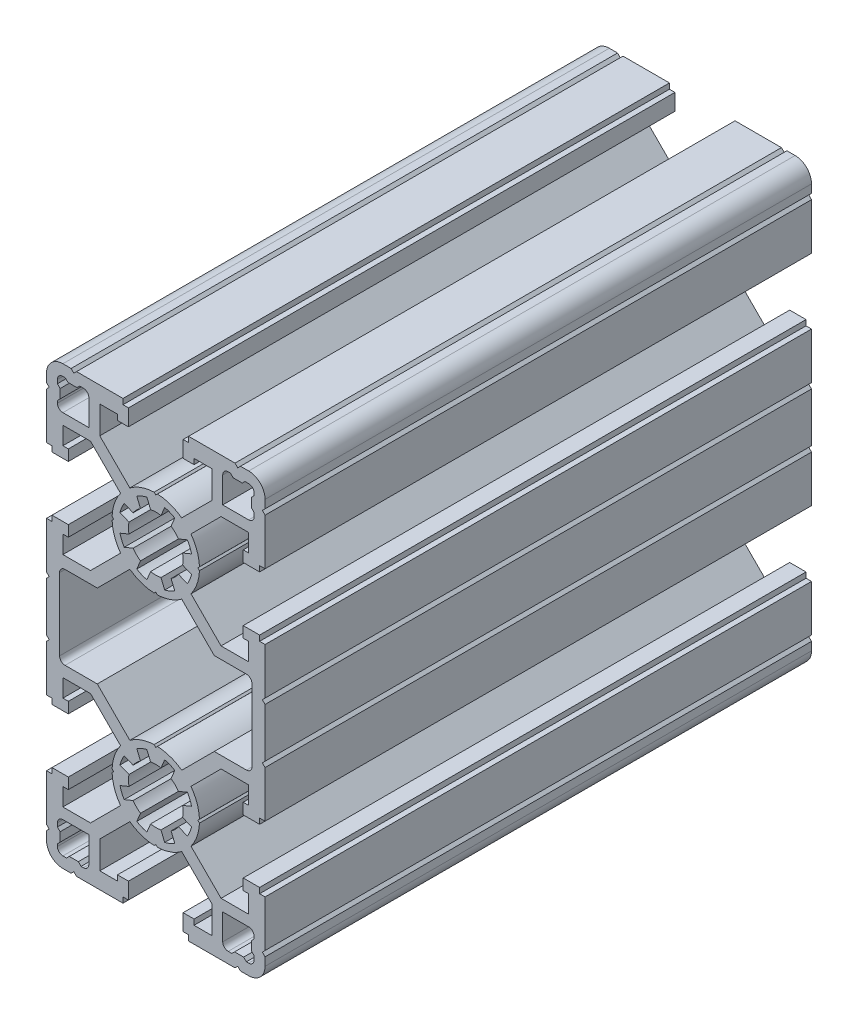
from build123d import *

# Parameters (mm, degrees)
Y_KSEKLIK_EKSTR_ZYON1_DEPTH = 100


with BuildPart() as part:
    # Çizim1 → Yükseklik-Ekstrüzyon1 (new body)
    with BuildSketch(Plane.XY.offset(100)):
        with BuildLine():
            Line((5, 35.999999999), (7.000000001, 35.999999999))
            Line((7.000000001, 35.999999999), (7.000000001, 36.999999999))
            Line((7.000000001, 36.999999999), (10.25, 36.999999999))
            Line((10.25, 36.999999999), (10.25, 31.947056271))
            Line((10.25, 31.947056271), (4.744324446, 26.441380719))
            ThreePointArc((4.744324446, 26.441380719), (2.642011935, 27.551143818), (0.30640597, 27.994130059))
            Line((0.30640597, 27.994130059), (1e-09, 27.700000001))
            Line((1e-09, 27.700000001), (-0.30640597, 27.994130059))
            ThreePointArc((-0.30640597, 27.994130059), (-2.642011934, 27.551143817), (-4.744324444, 26.441380719))
            Line((-4.744324444, 26.441380719), (-10.249999999, 31.947056274))
            Line((-10.249999999, 31.947056274), (-10.249999999, 36.999999999))
            Line((-10.249999999, 36.999999999), (-6.999999999, 36.999999999))
            Line((-6.999999999, 36.999999999), (-6.999999999, 35.999999999))
            Line((-6.999999999, 35.999999999), (-5, 35.999999999))
            Line((-5, 35.999999999), (-5, 39))
            Line((-5, 39), (-6, 39))
            Line((-6, 39), (-6, 40))
            Line((-6, 40), (-14.5, 40))
            Line((-14.5, 40), (-15, 39.5))
            Line((-15, 39.5), (-15.5, 40))
            Line((-15.5, 40), (-17, 40))
            ThreePointArc((-17, 40), (-19.121320344, 39.121320344), (-20, 37))
            Line((-20, 37), (-20, 35.5))
            Line((-20, 35.5), (-19.5, 35))
            Line((-19.5, 35), (-20, 34.5))
            Line((-20, 34.5), (-20, 26))
            Line((-20, 26), (-19, 26))
            Line((-19, 26), (-19, 25))
            Line((-19, 25), (-16, 25))
            Line((-16, 25), (-16, 27))
            Line((-16, 27), (-17, 27))
            Line((-17, 27), (-17, 30.25))
            Line((-17, 30.25), (-11.947056274, 30.25))
            Line((-11.947056274, 30.25), (-6.441380718, 24.744324445))
            ThreePointArc((-6.441380718, 24.744324445), (-7.551143816, 22.642011934), (-7.994130057, 20.30640597))
            Line((-7.994130057, 20.30640597), (-7.699999999, 20.000000001))
            Line((-7.699999999, 20.000000001), (-7.994130057, 19.69359403))
            ThreePointArc((-7.994130057, 19.69359403), (-7.551143816, 17.357988067), (-6.441380718, 15.255675557))
            Line((-6.441380718, 15.255675557), (-11.947056276, 9.75))
            Line((-11.947056276, 9.75), (-17, 9.75))
            Line((-17, 9.75), (-17, 13))
            Line((-17, 13), (-16, 13))
            Line((-16, 13), (-16, 15))
            Line((-16, 15), (-19, 15))
            Line((-19, 15), (-19, 14))
            Line((-19, 14), (-20, 14))
            Line((-20, 14), (-20, 5.5))
            Line((-20, 5.5), (-19.5, 5))
            Line((-19.5, 5), (-20, 4.5))
            Line((-20, 4.5), (-20, -4.5))
            Line((-20, -4.5), (-19.5, -5))
            Line((-19.5, -5), (-20, -5.5))
            Line((-20, -5.5), (-20, -14))
            Line((-20, -14), (-19, -14))
            Line((-19, -14), (-19, -15))
            Line((-19, -15), (-16, -15))
            Line((-16, -15), (-16, -13))
            Line((-16, -13), (-17, -13))
            Line((-17, -13), (-17, -9.750000001))
            Line((-17, -9.750000001), (-11.947056274, -9.750000001))
            Line((-11.947056274, -9.750000001), (-6.441380718, -15.255675557))
            ThreePointArc((-6.441380718, -15.255675557), (-7.551143816, -17.357988067), (-7.994130057, -19.69359403))
            Line((-7.994130057, -19.69359403), (-7.699999999, -20.000000001))
            Line((-7.699999999, -20.000000001), (-7.994130057, -20.30640597))
            ThreePointArc((-7.994130057, -20.30640597), (-7.551143816, -22.642011934), (-6.441380718, -24.744324445))
            Line((-6.441380718, -24.744324445), (-11.947056274, -30.25))
            Line((-11.947056274, -30.25), (-17, -30.25))
            Line((-17, -30.25), (-17, -27))
            Line((-17, -27), (-16, -27))
            Line((-16, -27), (-16, -25))
            Line((-16, -25), (-19, -25))
            Line((-19, -25), (-19, -26))
            Line((-19, -26), (-20, -26))
            Line((-20, -26), (-20, -34.5))
            Line((-20, -34.5), (-19.5, -35))
            Line((-19.5, -35), (-20, -35.5))
            Line((-20, -35.5), (-20, -37))
            ThreePointArc((-20, -37), (-19.121320344, -39.121320344), (-17, -40))
            Line((-17, -40), (-15.5, -40))
            Line((-15.5, -40), (-15, -39.5))
            Line((-15, -39.5), (-14.5, -40))
            Line((-14.5, -40), (-6, -40))
            Line((-6, -40), (-6, -39))
            Line((-6, -39), (-5, -39))
            Line((-5, -39), (-5, -36.000000001))
            Line((-5, -36.000000001), (-6.999999999, -36.000000001))
            Line((-6.999999999, -36.000000001), (-6.999999999, -37.000000001))
            Line((-6.999999999, -37.000000001), (-10.249999999, -37.000000001))
            Line((-10.249999999, -37.000000001), (-10.249999999, -31.947056276))
            Line((-10.249999999, -31.947056276), (-4.744324443, -26.44138072))
            ThreePointArc((-4.744324443, -26.44138072), (-2.642011933, -27.551143818), (-0.30640597, -27.994130059))
            Line((-0.30640597, -27.994130059), (1e-09, -27.700000001))
            Line((1e-09, -27.700000001), (0.30640597, -27.994130059))
            ThreePointArc((0.30640597, -27.994130059), (2.642011934, -27.551143818), (4.744324444, -26.441380721))
            Line((4.744324444, -26.441380721), (10.25, -31.947056276))
            Line((10.25, -31.947056276), (10.25, -37.000000001))
            Line((10.25, -37.000000001), (7.000000001, -37.000000001))
            Line((7.000000001, -37.000000001), (7.000000001, -36.000000001))
            Line((7.000000001, -36.000000001), (5, -36.000000001))
            Line((5, -36.000000001), (5, -39))
            Line((5, -39), (6, -39))
            Line((6, -39), (6, -40))
            Line((6, -40), (14.5, -40))
            Line((14.5, -40), (15, -39.5))
            Line((15, -39.5), (15.5, -40))
            Line((15.5, -40), (17, -40))
            ThreePointArc((17, -40), (19.121320344, -39.121320344), (20, -37))
            Line((20, -37), (20, -35.5))
            Line((20, -35.5), (19.5, -35))
            Line((19.5, -35), (20, -34.5))
            Line((20, -34.5), (20, -26))
            Line((20, -26), (19, -26))
            Line((19, -26), (19, -25))
            Line((19, -25), (16, -25))
            Line((16, -25), (16, -27))
            Line((16, -27), (17, -27))
            Line((17, -27), (17, -30.25))
            Line((17, -30.25), (11.947056275, -30.25))
            Line((11.947056275, -30.25), (6.44138072, -24.744324445))
            ThreePointArc((6.44138072, -24.744324445), (7.551143818, -22.642011935), (7.994130059, -20.306405972))
            Line((7.994130059, -20.306405972), (7.700000001, -20.000000001))
            Line((7.700000001, -20.000000001), (7.994130059, -19.693594032))
            ThreePointArc((7.994130059, -19.693594032), (7.551143818, -17.357988068), (6.44138072, -15.255675556))
            Line((6.44138072, -15.255675556), (11.947056275, -9.750000001))
            Line((11.947056275, -9.750000001), (17, -9.750000001))
            Line((17, -9.750000001), (17, -13))
            Line((17, -13), (16, -13))
            Line((16, -13), (16, -15))
            Line((16, -15), (19, -15))
            Line((19, -15), (19, -14))
            Line((19, -14), (20, -14))
            Line((20, -14), (20, -5.5))
            Line((20, -5.5), (19.5, -5))
            Line((19.5, -5), (20, -4.5))
            Line((20, -4.5), (20, 4.5))
            Line((20, 4.5), (19.5, 5))
            Line((19.5, 5), (20, 5.5))
            Line((20, 5.5), (20, 14))
            Line((20, 14), (19, 14))
            Line((19, 14), (19, 15))
            Line((19, 15), (16, 15))
            Line((16, 15), (16, 13))
            Line((16, 13), (17, 13))
            Line((17, 13), (17, 9.75))
            Line((17, 9.75), (11.947056273, 9.75))
            Line((11.947056273, 9.75), (6.441380719, 15.255675555))
            ThreePointArc((6.441380719, 15.255675555), (7.551143818, 17.357988067), (7.994130059, 19.693594032))
            Line((7.994130059, 19.693594032), (7.700000001, 20.000000001))
            Line((7.700000001, 20.000000001), (7.994130059, 20.306405972))
            ThreePointArc((7.994130059, 20.306405972), (7.551143818, 22.642011935), (6.44138072, 24.744324445))
            Line((6.44138072, 24.744324445), (11.947056275, 30.25))
            Line((11.947056275, 30.25), (17, 30.25))
            Line((17, 30.25), (17, 27))
            Line((17, 27), (16, 27))
            Line((16, 27), (16, 25))
            Line((16, 25), (19, 25))
            Line((19, 25), (19, 26))
            Line((19, 26), (20, 26))
            Line((20, 26), (20, 34.5))
            Line((20, 34.5), (19.5, 35))
            Line((19.5, 35), (20, 35.5))
            Line((20, 35.5), (20, 37))
            ThreePointArc((20, 37), (19.121320344, 39.121320344), (17, 40))
            Line((17, 40), (15.5, 40))
            Line((15.5, 40), (15, 39.5))
            Line((15, 39.5), (14.5, 40))
            Line((14.5, 40), (6, 40))
            Line((6, 40), (6, 39))
            Line((6, 39), (5, 39))
            Line((5, 39), (5, 35.999999999))
        make_face()
        with BuildLine():
            Line((1.630729447, -26.550055075), (0.950878753, -24.90875031))
            ThreePointArc((0.950878753, -24.90875031), (1e-09, -25.000000001), (-0.950878752, -24.90875031))
            Line((-0.950878752, -24.90875031), (-1.630729446, -26.550055075))
            ThreePointArc((-1.630729446, -26.550055075), (-2.583113167, -26.236186846), (-3.478488509, -25.784688211))
            Line((-3.478488509, -25.784688211), (-2.798637815, -24.143383446))
            ThreePointArc((-2.798637815, -24.143383446), (-3.535533905, -23.535533907), (-4.143383444, -22.798637818))
            Line((-4.143383444, -22.798637818), (-5.784688209, -23.478488512))
            ThreePointArc((-5.784688209, -23.478488512), (-6.236186844, -22.583113169), (-6.550055074, -21.630729446))
            Line((-6.550055074, -21.630729446), (-4.908750309, -20.950878752))
            ThreePointArc((-4.908750309, -20.950878752), (-4.999999999, -20), (-4.908750308, -19.049121248))
            Line((-4.908750308, -19.049121248), (-6.550055073, -18.369270554))
            ThreePointArc((-6.550055073, -18.369270554), (-6.236186844, -17.416886832), (-5.784688209, -16.52151149))
            Line((-5.784688209, -16.52151149), (-4.143383444, -17.201362184))
            ThreePointArc((-4.143383444, -17.201362184), (-3.535533905, -16.464466095), (-2.798637816, -15.856616556))
            Line((-2.798637816, -15.856616556), (-3.47848851, -14.215311791))
            ThreePointArc((-3.47848851, -14.215311791), (-2.583113167, -13.763813156), (-1.630729443, -13.449944926))
            Line((-1.630729443, -13.449944926), (-0.95087875, -15.091249691))
            ThreePointArc((-0.95087875, -15.091249691), (2e-09, -15.000000001), (0.950878753, -15.091249691))
            Line((0.950878753, -15.091249691), (1.630729447, -13.449944926))
            ThreePointArc((1.630729447, -13.449944926), (2.58311317, -13.763813156), (3.478488512, -14.215311791))
            Line((3.478488512, -14.215311791), (2.798637818, -15.856616556))
            ThreePointArc((2.798637818, -15.856616556), (3.535533907, -16.464466095), (4.143383446, -17.201362184))
            Line((4.143383446, -17.201362184), (5.784688211, -16.52151149))
            ThreePointArc((5.784688211, -16.52151149), (6.236186846, -17.416886832), (6.550055075, -18.369270554))
            Line((6.550055075, -18.369270554), (4.90875031, -19.049121248))
            ThreePointArc((4.90875031, -19.049121248), (5.000000001, -20.000000001), (4.90875031, -20.950878754))
            Line((4.90875031, -20.950878754), (6.550055075, -21.630729448))
            ThreePointArc((6.550055075, -21.630729448), (6.236186845, -22.58311317), (5.78468821, -23.478488513))
            Line((5.78468821, -23.478488513), (4.143383445, -22.798637819))
            ThreePointArc((4.143383445, -22.798637819), (3.535533907, -23.535533907), (2.798637818, -24.143383446))
            Line((2.798637818, -24.143383446), (3.478488511, -25.784688211))
            ThreePointArc((3.478488511, -25.784688211), (2.583113169, -26.236186846), (1.630729447, -26.550055075))
        make_face(mode=Mode.SUBTRACT)
        with BuildLine():
            Line((17, -38), (16.578427125, -38))
            Line((16.578427125, -38), (16.078427125, -37.5))
            Line((16.078427125, -37.5), (14.421572875, -37.5))
            Line((14.421572875, -37.5), (13.921572875, -38))
            Line((13.921572875, -38), (13.25, -38))
            ThreePointArc((13.25, -38), (12.542893219, -37.707106781), (12.25, -37))
            Line((12.25, -37), (12.25, -32.25))
            Line((12.25, -32.25), (17, -32.25))
            ThreePointArc((17, -32.25), (17.707106781, -32.542893219), (18, -33.25))
            Line((18, -33.25), (18, -33.671572875))
            Line((18, -33.671572875), (17.5, -34.171572875))
            Line((17.5, -34.171572875), (17.5, -35.828427125))
            Line((17.5, -35.828427125), (18, -36.328427125))
            Line((18, -36.328427125), (18, -37))
            ThreePointArc((18, -37), (17.707106781, -37.707106781), (17, -38))
        make_face(mode=Mode.SUBTRACT)
        with BuildLine():
            Line((-18, -37), (-18, -36.578427125))
            Line((-18, -36.578427125), (-17.5, -36.078427125))
            Line((-17.5, -36.078427125), (-17.5, -34.421572875))
            Line((-17.5, -34.421572875), (-18, -33.921572875))
            Line((-18, -33.921572875), (-18, -33.25))
            ThreePointArc((-18, -33.25), (-17.707106781, -32.542893219), (-17, -32.25))
            Line((-17, -32.25), (-12.25, -32.25))
            Line((-12.25, -32.25), (-12.25, -37))
            ThreePointArc((-12.25, -37), (-12.542893219, -37.707106781), (-13.25, -38))
            Line((-13.25, -38), (-13.671572875, -38))
            Line((-13.671572875, -38), (-14.171572875, -37.5))
            Line((-14.171572875, -37.5), (-15.828427125, -37.5))
            Line((-15.828427125, -37.5), (-16.328427125, -38))
            Line((-16.328427125, -38), (-17, -38))
            ThreePointArc((-17, -38), (-17.707106781, -37.707106781), (-18, -37))
        make_face(mode=Mode.SUBTRACT)
        with BuildLine():
            Line((18, 37), (18, 36.578427125))
            Line((18, 36.578427125), (17.5, 36.078427125))
            Line((17.5, 36.078427125), (17.5, 34.421572875))
            Line((17.5, 34.421572875), (18, 33.921572875))
            Line((18, 33.921572875), (18, 33.25))
            ThreePointArc((18, 33.25), (17.707106781, 32.542893219), (17, 32.25))
            Line((17, 32.25), (12.25, 32.25))
            Line((12.25, 32.25), (12.25, 37))
            ThreePointArc((12.25, 37), (12.542893219, 37.707106781), (13.25, 38))
            Line((13.25, 38), (13.671572875, 38))
            Line((13.671572875, 38), (14.171572875, 37.5))
            Line((14.171572875, 37.5), (15.828427125, 37.5))
            Line((15.828427125, 37.5), (16.328427125, 38))
            Line((16.328427125, 38), (17, 38))
            ThreePointArc((17, 38), (17.707106781, 37.707106781), (18, 37))
        make_face(mode=Mode.SUBTRACT)
        with BuildLine():
            Line((-17, 38), (-16.578427125, 38))
            Line((-16.578427125, 38), (-16.078427125, 37.5))
            Line((-16.078427125, 37.5), (-14.421572875, 37.5))
            Line((-14.421572875, 37.5), (-13.921572875, 38))
            Line((-13.921572875, 38), (-13.25, 38))
            ThreePointArc((-13.25, 38), (-12.542893219, 37.707106781), (-12.25, 37))
            Line((-12.25, 37), (-12.25, 32.25))
            Line((-12.25, 32.25), (-17, 32.25))
            ThreePointArc((-17, 32.25), (-17.707106781, 32.542893219), (-18, 33.25))
            Line((-18, 33.25), (-18, 33.671572875))
            Line((-18, 33.671572875), (-17.5, 34.171572875))
            Line((-17.5, 34.171572875), (-17.5, 35.828427125))
            Line((-17.5, 35.828427125), (-18, 36.328427125))
            Line((-18, 36.328427125), (-18, 37))
            ThreePointArc((-18, 37), (-17.707106781, 37.707106781), (-17, 38))
        make_face(mode=Mode.SUBTRACT)
        with BuildLine():
            Line((17.600000001, 6.600000001), (17.600000001, -6.600000001))
            ThreePointArc((17.600000001, -6.600000001), (17.307106782, -7.307106782), (16.600000001, -7.600000001))
            Line((16.600000001, -7.600000001), (10.702943726, -7.600000001))
            Line((10.702943726, -7.600000001), (4.744324445, -13.558619281))
            ThreePointArc((4.744324445, -13.558619281), (2.642011935, -12.448856184), (0.306405972, -12.005869943))
            Line((0.306405972, -12.005869943), (1e-09, -12.300000001))
            Line((1e-09, -12.300000001), (-0.306405968, -12.005869943))
            ThreePointArc((-0.306405968, -12.005869943), (-2.642011933, -12.448856184), (-4.744324444, -13.558619283))
            Line((-4.744324444, -13.558619283), (-10.702943727, -7.600000001))
            Line((-10.702943727, -7.600000001), (-16.599999999, -7.600000001))
            ThreePointArc((-16.599999999, -7.600000001), (-17.307106781, -7.307106782), (-17.599999999, -6.600000001))
            Line((-17.599999999, -6.600000001), (-17.599999999, 6.600000001))
            ThreePointArc((-17.599999999, 6.600000001), (-17.307106781, 7.307106782), (-16.599999999, 7.600000001))
            Line((-16.599999999, 7.600000001), (-10.702943727, 7.600000001))
            Line((-10.702943727, 7.600000001), (-4.744324444, 13.558619283))
            ThreePointArc((-4.744324444, 13.558619283), (-2.642011933, 12.448856184), (-0.306405968, 12.005869943))
            Line((-0.306405968, 12.005869943), (1e-09, 12.300000001))
            Line((1e-09, 12.300000001), (0.306405972, 12.005869943))
            ThreePointArc((0.306405972, 12.005869943), (2.642011935, 12.448856184), (4.744324445, 13.558619281))
            Line((4.744324445, 13.558619281), (10.702943726, 7.600000001))
            Line((10.702943726, 7.600000001), (16.600000001, 7.600000001))
            ThreePointArc((16.600000001, 7.600000001), (17.307106782, 7.307106782), (17.600000001, 6.600000001))
        make_face(mode=Mode.SUBTRACT)
        with BuildLine():
            Line((1.630729447, 13.449944926), (0.950878753, 15.091249692))
            ThreePointArc((0.950878753, 15.091249692), (1e-09, 15.000000001), (-0.950878752, 15.091249692))
            Line((-0.950878752, 15.091249692), (-1.630729446, 13.449944927))
            ThreePointArc((-1.630729446, 13.449944927), (-2.583113167, 13.763813156), (-3.478488509, 14.215311791))
            Line((-3.478488509, 14.215311791), (-2.798637815, 15.856616556))
            ThreePointArc((-2.798637815, 15.856616556), (-3.535533905, 16.464466095), (-4.143383444, 17.201362184))
            Line((-4.143383444, 17.201362184), (-5.784688209, 16.52151149))
            ThreePointArc((-5.784688209, 16.52151149), (-6.236186844, 17.416886833), (-6.550055074, 18.369270556))
            Line((-6.550055074, 18.369270556), (-4.908750309, 19.049121249))
            ThreePointArc((-4.908750309, 19.049121249), (-4.999999999, 20.000000002), (-4.908750308, 20.950878754))
            Line((-4.908750308, 20.950878754), (-6.550055073, 21.630729448))
            ThreePointArc((-6.550055073, 21.630729448), (-6.236186844, 22.58311317), (-5.784688209, 23.478488512))
            Line((-5.784688209, 23.478488512), (-4.143383444, 22.798637818))
            ThreePointArc((-4.143383444, 22.798637818), (-3.535533905, 23.535533907), (-2.798637816, 24.143383446))
            Line((-2.798637816, 24.143383446), (-3.47848851, 25.784688211))
            ThreePointArc((-3.47848851, 25.784688211), (-2.583113167, 26.236186846), (-1.630729443, 26.550055076))
            Line((-1.630729443, 26.550055076), (-0.95087875, 24.908750311))
            ThreePointArc((-0.95087875, 24.908750311), (2e-09, 25.000000001), (0.950878753, 24.90875031))
            Line((0.950878753, 24.90875031), (1.630729447, 26.550055075))
            ThreePointArc((1.630729447, 26.550055075), (2.58311317, 26.236186846), (3.478488512, 25.784688211))
            Line((3.478488512, 25.784688211), (2.798637818, 24.143383446))
            ThreePointArc((2.798637818, 24.143383446), (3.535533907, 23.535533907), (4.143383446, 22.798637818))
            Line((4.143383446, 22.798637818), (5.784688211, 23.478488511))
            ThreePointArc((5.784688211, 23.478488511), (6.236186846, 22.58311317), (6.550055075, 21.630729448))
            Line((6.550055075, 21.630729448), (4.90875031, 20.950878754))
            ThreePointArc((4.90875031, 20.950878754), (5.000000001, 20.000000001), (4.90875031, 19.049121248))
            Line((4.90875031, 19.049121248), (6.550055075, 18.369270554))
            ThreePointArc((6.550055075, 18.369270554), (6.236186845, 17.416886831), (5.78468821, 16.521511489))
            Line((5.78468821, 16.521511489), (4.143383445, 17.201362183))
            ThreePointArc((4.143383445, 17.201362183), (3.535533907, 16.464466094), (2.798637818, 15.856616556))
            Line((2.798637818, 15.856616556), (3.478488511, 14.215311791))
            ThreePointArc((3.478488511, 14.215311791), (2.583113169, 13.763813156), (1.630729447, 13.449944926))
        make_face(mode=Mode.SUBTRACT)
    extrude(amount=-Y_KSEKLIK_EKSTR_ZYON1_DEPTH)


solid = part.part
